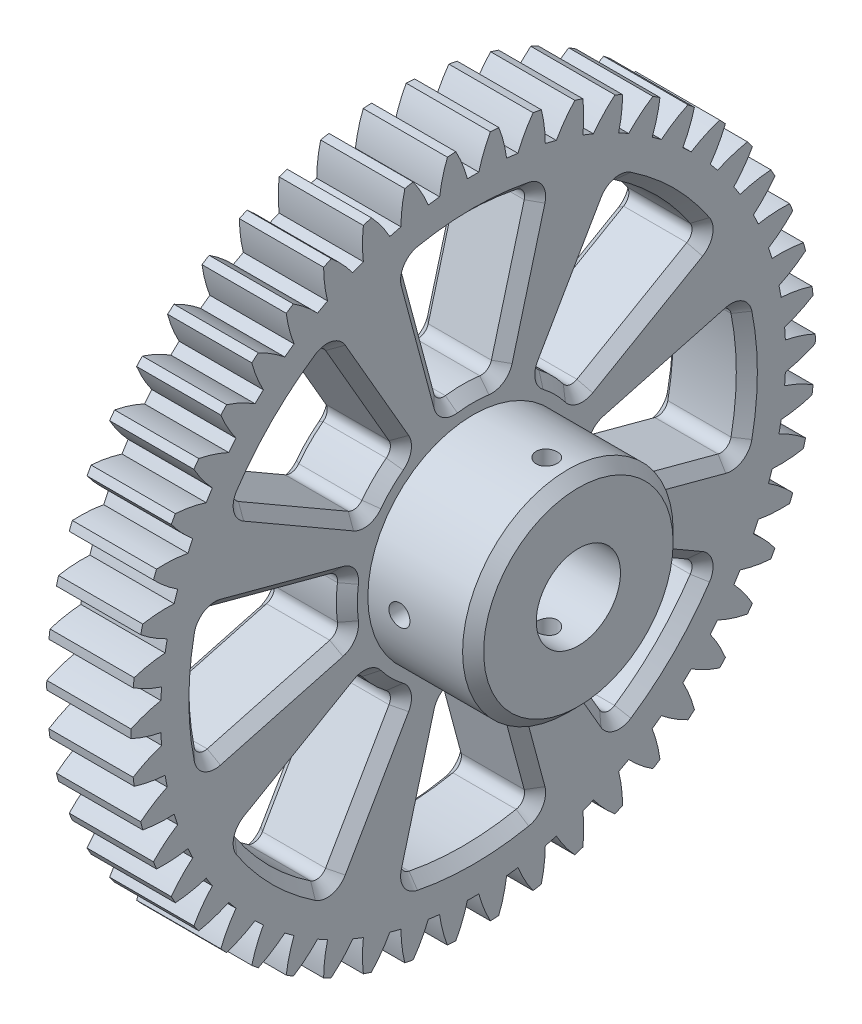
from build123d import *
from build123d.topology import SkipClean

# Parameters (mm, degrees)
BASPROSKE_W                          = 8
BASPROSKE_H                          = 32.5
TOOTHCUT_DEPTH                       = 47.652974182
TEETHCUTS_COUNT                      = 50
TEETHCUTS_ANGLE                      = 352.8
BORSKE_R                             = 4
BORE_DEPTH                           = 50.0004572
EXTRUDE_START                        = 10
SKETCH_1_R                           = 10
SKETCH_1_R_2                         = 4
EXTRUDE_1_DEPTH                      = 10
CUT_EXTRUDE_1_DEPTH                  = 50.333649311
CUT_EXTRUDE_1_DEPTH_BACK             = 50.333649311
CUT_EXTRUDE_2_DEPTH                  = 50.333649347
CUT_EXTRUDE_2_DEPTH_BACK             = 50.333649347
CHAMFER_1_SIZE                       = 1
CHAMFER_2_SIZE                       = 1
CUT_EXTRUDE_3_DEPTH                  = 48.008605131
FILLET_1_R                           = 1
CHAMFER_3_SIZE                       = 1
PATTERN_CIRCULAR_1_COUNT             = 8
FILLET_1_OF_PATTERN_CIRCULAR_1_R     = 1
CHAMFER_3_OF_PATTERN_CIRCULAR_1_SIZE = 1


with BuildPart() as part:
    # BasProSke → Base-Revolve (revolve)
    with BuildSketch(Plane(origin=(0, 0, 0), x_dir=(1, 0, 0), z_dir=(0, 1, 0)), mode=Mode.PRIVATE) as base_revolve_sk:
        with Locations((4, 16.25)):
            Rectangle(BASPROSKE_W, BASPROSKE_H)
    revolve(base_revolve_sk.sketch.rotate(Axis((-10, 0, 0), (1, 0, 0)), 180), axis=Axis((-10, 0, 0), (1, 0, 0)))

    # TooCutSke → ToothCut (cut, through all)
    with BuildSketch(Plane(origin=(0, 0, 0), x_dir=(0, 0, -1), z_dir=(1, 0, 0))):
        with BuildLine():
            ThreePointArc((0.542987455, 29.681533769), (0, 29.6865), (-0.542987455, 29.681533769))
            ThreePointArc((-0.542987455, 29.681533769), (-1.01367548, 31.116033427), (-1.653872687, 32.483324188))
            ThreePointArc((-1.653872687, 32.483324188), (0, 32.5254), (1.653872687, 32.483324188))
            ThreePointArc((1.653872687, 32.483324188), (1.01367548, 31.116033427), (0.542987455, 29.681533769))
        make_face()
    toothcut = extrude(amount=TOOTHCUT_DEPTH, mode=Mode.SUBTRACT)

    # TeethCuts: ToothCut ×50 about axis
    teethcuts_axis = Axis((-10, 0, 0), (1, 0, 0))
    for i in range(1, TEETHCUTS_COUNT):
        add(toothcut.rotate(teethcuts_axis, i * TEETHCUTS_ANGLE / (TEETHCUTS_COUNT - 1)), mode=Mode.SUBTRACT)

    # BorSke → Bore (cut, symmetric)
    with BuildSketch(Plane(origin=(0, 0, 0), x_dir=(0, 0, -1), z_dir=(1, 0, 0))):
        with Locations(Location((0, 0, 0), (0, 0, 180))):
            Circle(BORSKE_R)
    extrude(amount=BORE_DEPTH, both=True, mode=Mode.SUBTRACT)

    # Эскиз1 → Бобышка-Вытянуть1 (add)
    with BuildSketch(Plane(origin=(8, 0, 0), x_dir=(0, 0, -1), z_dir=(1, 0, 0)).offset(EXTRUDE_START)):
        with Locations(Location((0, 0, 0), (0, 0, 180))):
            Circle(SKETCH_1_R)
        Circle(SKETCH_1_R_2, mode=Mode.SUBTRACT)
    extrude(amount=-EXTRUDE_1_DEPTH)

    # Эскиз2 → Вырез-Вытянуть1 (cut, two sides: drawn at the far end of the back side and taken through both)
    with SkipClean():  # the faces are left unmerged after this step: merging them gives an invalid solid
        with BuildSketch(Plane(origin=(0, 0, 0), x_dir=(1, 0, 0), z_dir=(0, 1, 0)).offset(-CUT_EXTRUDE_1_DEPTH_BACK)):
            with BuildLine():
                ThreePointArc((14, 0), (15, -1), (16, 0))
                Line((16, 0), (14, 0))
            make_face()
            with BuildLine():
                Line((14, 0), (16, 0))
                ThreePointArc((16, 0), (15, 1), (14, 0))
            make_face()
        extrude(amount=CUT_EXTRUDE_1_DEPTH + CUT_EXTRUDE_1_DEPTH_BACK, mode=Mode.SUBTRACT)

    # Эскиз3 → Вырез-Вытянуть2 (cut, two sides: drawn at the far end of the back side and taken through both)
    with SkipClean():  # the faces are left unmerged after this step: merging them gives an invalid solid
        with BuildSketch(Plane.XY.offset(-CUT_EXTRUDE_2_DEPTH_BACK)):
            with BuildLine():
                ThreePointArc((10, 0), (11, -1), (12, 0))
                Line((12, 0), (10, 0))
            make_face()
            with BuildLine():
                Line((10, 0), (12, 0))
                ThreePointArc((12, 0), (11, 1), (10, 0))
            make_face()
        extrude(amount=CUT_EXTRUDE_2_DEPTH + CUT_EXTRUDE_2_DEPTH_BACK, mode=Mode.SUBTRACT)

    # Фаска1
    chamfer_1_edges = [part.edges().sort_by_distance(p)[0] for p in [
        (18, 0, -10),
    ]]
    chamfer(chamfer_1_edges, length=CHAMFER_1_SIZE)

    # Фаска2
    chamfer_2_edges = [part.edges().sort_by_distance(p)[0] for p in [
        (0, 0, -4),
    ]]
    chamfer(chamfer_2_edges, length=CHAMFER_2_SIZE)

    # Эскиз4 → Вырез-Вытянуть3 (cut, symmetric)
    with SkipClean():  # the faces are left unmerged after this step: merging them gives an invalid solid
        with BuildSketch(Plane(origin=(8, 0, 0), x_dir=(0, 0, -1), z_dir=(1, 0, 0))):
            with BuildLine():
                Line((-11.736694594, 2.5), (-25.268073332, 6.125722005))
                ThreePointArc((-25.268073332, 6.125722005), (-26, 0), (-25.268073332, -6.125722005))
                Line((-25.268073332, -6.125722005), (-11.736694594, -2.5))
                ThreePointArc((-11.736694594, -2.5), (-12, 0), (-11.736694594, 2.5))
            make_face()
        cut_extrude_3 = extrude(amount=CUT_EXTRUDE_3_DEPTH, both=True, mode=Mode.SUBTRACT)

    # Скругление1
    fillet_1_edges = [part.edges().sort_by_distance(p)[0] for p in [
        (4, 6.125722005, 25.268073332),
        (4, 2.5, 11.736694594),
        (4, -2.5, 11.736694594),
        (4, -6.125722005, 25.268073332),
    ]]
    fillet(fillet_1_edges, radius=FILLET_1_R)

    # Фаска3
    chamfer_3_edges = [part.edges().sort_by_distance(p)[0] for p in [
        (0, 4.295936146, 18.43921954),
        (8, 4.295936146, 18.43921954),
        (8, 0, 12),
        (0, 0, 12),
        (8, -4.295936146, 18.43921954),
        (0, -4.295936146, 18.43921954),
        (0, 0, 26),
        (8, 0, 26),
        (8, 2.323942355, 12.045775814),
        (0, 2.323942355, 12.045775814),
        (8, -2.323942355, 12.045775814),
        (0, -2.323942355, 12.045775814),
        (8, 5.738592433, 25.045101389),
        (0, 5.738592433, 25.045101389),
        (8, -5.738592433, 25.045101389),
        (0, -5.738592433, 25.045101389),
    ]]
    chamfer(chamfer_3_edges, length=CHAMFER_3_SIZE)

    # Круговой массив1: Вырез-Вытянуть3 ×8 about axis
    with SkipClean():  # the faces are left unmerged after this step: merging them gives an invalid solid
        pattern_circular_1_axis = Axis((0, 0, 0), (1, 0, 0))
        for i in range(1, PATTERN_CIRCULAR_1_COUNT):
            add(cut_extrude_3.rotate(pattern_circular_1_axis, i * 360 / PATTERN_CIRCULAR_1_COUNT), mode=Mode.SUBTRACT)

    # Скругление1 of Круговой массив1
    fillet_1_of_pattern_circular_1_edges = [part.edges().sort_by_distance(p)[0] for p in [
        (4, -13.535686431, 22.19876557),
        (4, -6.531329383, 10.066863289),
        (4, -10.066863289, 6.531329383),
        (4, -22.19876557, 13.535686431),
        (4, -25.268073332, 6.125722005),
        (4, -11.736694594, 2.5),
        (4, -11.736694594, -2.5),
        (4, -25.268073332, -6.125722005),
        (4, -22.19876557, -13.535686431),
        (4, -10.066863289, -6.531329383),
        (4, -6.531329383, -10.066863289),
        (4, -13.535686431, -22.19876557),
        (4, -6.125722005, -25.268073332),
        (4, -2.5, -11.736694594),
        (4, 2.5, -11.736694594),
        (4, 6.125722005, -25.268073332),
        (4, 13.535686431, -22.19876557),
        (4, 6.531329383, -10.066863289),
        (4, 10.066863289, -6.531329383),
        (4, 22.19876557, -13.535686431),
        (4, 25.268073332, -6.125722005),
        (4, 11.736694594, -2.5),
        (4, 11.736694594, 2.5),
        (4, 25.268073332, 6.125722005),
        (4, 22.19876557, 13.535686431),
        (4, 10.066863289, 6.531329383),
        (4, 6.531329383, 10.066863289),
        (4, 13.535686431, 22.19876557),
    ]]
    fillet(fillet_1_of_pattern_circular_1_edges, radius=FILLET_1_OF_PATTERN_CIRCULAR_1_R)

    # Фаска3 of Круговой массив1
    chamfer_3_of_pattern_circular_1_edges = [part.edges().sort_by_distance(p)[0] for p in [
        (0, -10.000811596, 16.076182757),
        (8, -10.000811596, 16.076182757),
        (8, -8.485281374, 8.485281374),
        (0, -8.485281374, 8.485281374),
        (8, -16.076182757, 10.000811596),
        (0, -16.076182757, 10.000811596),
        (0, -18.384776311, 18.384776311),
        (8, -18.384776311, 18.384776311),
        (8, -6.874374364, 10.160925161),
        (0, -6.874374364, 10.160925161),
        (8, -10.160925161, 6.874374364),
        (0, -10.160925161, 6.874374364),
        (8, -13.651763404, 21.767358651),
        (0, -13.651763404, 21.767358651),
        (8, -21.767358651, 13.651763404),
        (0, -21.767358651, 13.651763404),
        (0, -18.43921954, 4.295936146),
        (8, -18.43921954, 4.295936146),
        (8, -12, 0),
        (0, -12, 0),
        (8, -18.43921954, -4.295936146),
        (0, -18.43921954, -4.295936146),
        (0, -26, 0),
        (8, -26, 0),
        (8, -12.045775814, 2.323942355),
        (0, -12.045775814, 2.323942355),
        (8, -12.045775814, -2.323942355),
        (0, -12.045775814, -2.323942355),
        (8, -25.045101389, 5.738592433),
        (0, -25.045101389, 5.738592433),
        (8, -25.045101389, -5.738592433),
        (0, -25.045101389, -5.738592433),
        (0, -16.076182757, -10.000811596),
        (8, -16.076182757, -10.000811596),
        (8, -8.485281374, -8.485281374),
        (0, -8.485281374, -8.485281374),
        (8, -10.000811596, -16.076182757),
        (0, -10.000811596, -16.076182757),
        (0, -18.384776311, -18.384776311),
        (8, -18.384776311, -18.384776311),
        (8, -10.160925161, -6.874374364),
        (0, -10.160925161, -6.874374364),
        (8, -6.874374364, -10.160925161),
        (0, -6.874374364, -10.160925161),
        (8, -21.767358651, -13.651763404),
        (0, -21.767358651, -13.651763404),
        (8, -13.651763404, -21.767358651),
        (0, -13.651763404, -21.767358651),
        (0, -4.295936146, -18.43921954),
        (8, -4.295936146, -18.43921954),
        (8, 0, -12),
        (0, 0, -12),
        (8, 4.295936146, -18.43921954),
        (0, 4.295936146, -18.43921954),
        (0, 0, -26),
        (8, 0, -26),
        (8, -2.323942355, -12.045775814),
        (0, -2.323942355, -12.045775814),
        (8, 2.323942355, -12.045775814),
        (0, 2.323942355, -12.045775814),
        (8, -5.738592433, -25.045101389),
        (0, -5.738592433, -25.045101389),
        (8, 5.738592433, -25.045101389),
        (0, 5.738592433, -25.045101389),
        (0, 10.000811596, -16.076182757),
        (8, 10.000811596, -16.076182757),
        (8, 8.485281374, -8.485281374),
        (0, 8.485281374, -8.485281374),
        (8, 16.076182757, -10.000811596),
        (0, 16.076182757, -10.000811596),
        (0, 18.384776311, -18.384776311),
        (8, 18.384776311, -18.384776311),
        (8, 6.874374364, -10.160925161),
        (0, 6.874374364, -10.160925161),
        (8, 10.160925161, -6.874374364),
        (0, 10.160925161, -6.874374364),
        (8, 13.651763404, -21.767358651),
        (0, 13.651763404, -21.767358651),
        (8, 21.767358651, -13.651763404),
        (0, 21.767358651, -13.651763404),
        (0, 18.43921954, -4.295936146),
        (8, 18.43921954, -4.295936146),
        (8, 12, 0),
        (0, 12, 0),
        (8, 18.43921954, 4.295936146),
        (0, 18.43921954, 4.295936146),
        (0, 26, 0),
        (8, 26, 0),
        (8, 12.045775814, -2.323942355),
        (0, 12.045775814, -2.323942355),
        (8, 12.045775814, 2.323942355),
        (0, 12.045775814, 2.323942355),
        (8, 25.045101389, -5.738592433),
        (0, 25.045101389, -5.738592433),
        (8, 25.045101389, 5.738592433),
        (0, 25.045101389, 5.738592433),
        (0, 16.076182757, 10.000811596),
        (8, 16.076182757, 10.000811596),
        (8, 8.485281374, 8.485281374),
        (0, 8.485281374, 8.485281374),
        (8, 10.000811596, 16.076182757),
        (0, 10.000811596, 16.076182757),
        (0, 18.384776311, 18.384776311),
        (8, 18.384776311, 18.384776311),
        (8, 10.160925161, 6.874374364),
        (0, 10.160925161, 6.874374364),
        (8, 6.874374364, 10.160925161),
        (0, 6.874374364, 10.160925161),
        (8, 21.767358651, 13.651763404),
        (0, 21.767358651, 13.651763404),
        (8, 13.651763404, 21.767358651),
        (0, 13.651763404, 21.767358651),
    ]]
    chamfer(chamfer_3_of_pattern_circular_1_edges, length=CHAMFER_3_OF_PATTERN_CIRCULAR_1_SIZE)


solid = part.part
